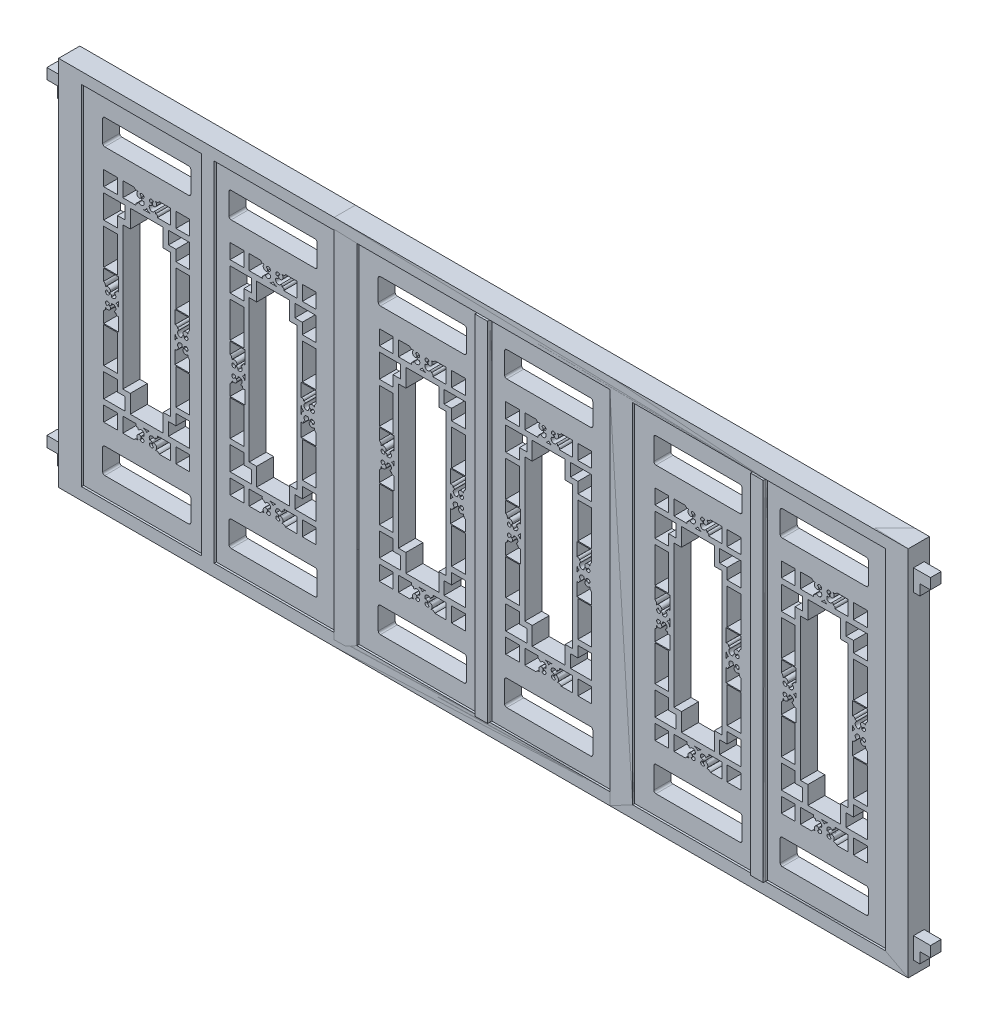
from build123d import *

# Parameters (mm, degrees)
SKETCH1_W                = 595
SKETCH1_H                = 1640
BOSS_EXTRUDE1_DEPTH      = 180
SKETCH_6_W               = 595
SKETCH_6_H               = 1640
CUT_EXTRUDE_2_DEPTH      = 100
CUT_EXTRUDE_3_DEPTH      = 100
SKETCH2_W                = 65
SKETCH2_H                = 70
SKETCH2_H_2              = 167
CUT_EXTRUDE_5_DEPTH      = 81
CUT_EXTRUDE_8_DEPTH      = 81
PATTERN_LINEAR_1_COUNT   = 2
PATTERN_LINEAR_1_PITCH   = 595
SKETCH_7_W               = 4000
SKETCH_7_H               = 1750
SKETCH_7_W_2             = 1190
SKETCH_7_H_2             = 1640
EXTRUDE_2_DEPTH          = 90
EXTRUDE_2_DEPTH_BACK     = 10
EXTRUDE_3_DEPTH          = 10
EXTRUDE_3_DEPTH_BACK     = 90
SKETCH_9_W               = 60
SKETCH_9_H               = 1640
EXTRUDE_4_DEPTH          = 100
PATTERN_LINEAR_2_COUNT   = 3
PATTERN_LINEAR_2_PITCH   = 1297.5
SKETCH_11_W              = 2595
SKETCH_11_H              = 1750
CUT_EXTRUDE_9_DEPTH      = 111
SKETCH_12_W              = 50
SKETCH_12_H              = 100
EXTRUDE_5_DEPTH          = 80
SKETCH_13_W              = 50
SKETCH_13_H              = 50
CUT_EXTRUDE_10_DEPTH     = 50
PATTERN_LINEAR_3_COUNT   = 2
PATTERN_LINEAR_3_PITCH   = 1500
MIRROR_4_COPY_1_SKETCH_W = 50
MIRROR_4_COPY_1_SKETCH_H = 100
MIRROR_4_COPY_1_DEPTH    = 80
MIRROR_4_COPY_2_SKETCH_W = 50
MIRROR_4_COPY_2_SKETCH_H = 50
MIRROR_4_COPY_2_DEPTH    = 50


with BuildPart() as part:
    # Sketch1 → Boss-Extrude1 (new body)
    with BuildSketch(Plane.XY):
        with Locations((297.5, 820)):
            Rectangle(SKETCH1_W, SKETCH1_H)
    extrude(amount=BOSS_EXTRUDE1_DEPTH)

    # Sketch 6 → Cut-Extrude 2 (cut)
    with BuildSketch(Plane.XY.offset(180)):
        with Locations((297.5, 820)):
            Rectangle(SKETCH_6_W, SKETCH_6_H)
    extrude(amount=-CUT_EXTRUDE_2_DEPTH, mode=Mode.SUBTRACT)

    # Sketch 1 → Cut-Extrude 3 (cut)
    with BuildSketch(Plane(origin=(0, 0, 0), x_dir=(-1, 0, 0), z_dir=(0, 0, -1))):
        with BuildLine():
            ThreePointArc((-339.478697135, 363.442307012), (-347.464207716, 366.462464977), (-347.449072001, 375))
            Line((-347.449072001, 375), (-410, 375))
            Line((-410, 375), (-410, 305))
            Line((-410, 305), (-356.673331708, 305))
            ThreePointArc((-356.673331708, 305), (-348.94904931, 312.012889726), (-338.529552639, 312.541330816))
            ThreePointArc((-338.529552639, 312.541330816), (-344.046220029, 325.924483031), (-334.768909443, 337.036363636))
            ThreePointArc((-334.768909443, 337.036363636), (-323.949287324, 331.726907665), (-329.315168468, 320.935157804))
            ThreePointArc((-329.315168468, 320.935157804), (-314.478603669, 315.069270244), (-315.214046212, 331.006378394))
            ThreePointArc((-315.214046212, 331.006378394), (-318.365986632, 330.765395418), (-320.358708006, 328.311447022))
            ThreePointArc((-320.358708006, 328.311447022), (-320.882047686, 338.069212343), (-311.577227356, 341.053870966))
            ThreePointArc((-311.577227356, 341.053870966), (-311.192434776, 341.798442865), (-310.72696898, 342.495432272))
            ThreePointArc((-310.72696898, 342.495432272), (-316.343126273, 360.498534643), (-334.477239272, 355.321000146))
            ThreePointArc((-334.477239272, 355.321000146), (-338.751843962, 358.289222889), (-339.478697135, 363.442307012))
        make_face()
        with BuildLine():
            Line((-185, 375), (-247.550927999, 375))
            ThreePointArc((-247.550927999, 375), (-247.535792284, 366.462464977), (-255.521302865, 363.442307012))
            ThreePointArc((-255.521302865, 363.442307012), (-256.248156038, 358.289222889), (-260.522760728, 355.321000146))
            ThreePointArc((-260.522760728, 355.321000146), (-278.656873727, 360.498534643), (-284.27303102, 342.495432272))
            ThreePointArc((-284.27303102, 342.495432272), (-283.807565224, 341.798442865), (-283.422772644, 341.053870966))
            ThreePointArc((-283.422772644, 341.053870966), (-274.117952314, 338.069212343), (-274.641291994, 328.311447022))
            ThreePointArc((-274.641291994, 328.311447022), (-276.634013368, 330.765395418), (-279.785953788, 331.006378394))
            ThreePointArc((-279.785953788, 331.006378394), (-280.521396331, 315.069270244), (-265.684831532, 320.935157804))
            ThreePointArc((-265.684831532, 320.935157804), (-271.050712676, 331.726907665), (-260.231090557, 337.036363636))
            ThreePointArc((-260.231090557, 337.036363636), (-250.953779971, 325.924483031), (-256.470447361, 312.541330816))
            ThreePointArc((-256.470447361, 312.541330816), (-246.05095069, 312.012889726), (-238.326668292, 305))
            Line((-238.326668292, 305), (-185, 305))
            Line((-185, 305), (-185, 375))
        make_face()
        with BuildLine():
            ThreePointArc((-279.5, 375), (-290.126074317, 371.412833197), (-297.5, 362.9626))
            ThreePointArc((-297.5, 362.9626), (-304.873925683, 371.412833197), (-315.5, 375))
            Line((-315.5, 375), (-279.5, 375))
        make_face()
    cut_extrude_3 = extrude(amount=-CUT_EXTRUDE_3_DEPTH, mode=Mode.SUBTRACT)

    # Sketch2 → Cut-Extrude 5 (cut, through all)
    with BuildSketch(Plane(origin=(0, 0, 0), x_dir=(-1, 0, 0), z_dir=(0, 0, -1))):
        with BuildLine():
            Line((-100, 90), (-495, 90))
            ThreePointArc((-495, 90), (-502.071067812, 92.928932188), (-505, 100))
            Line((-505, 100), (-505, 200))
            ThreePointArc((-505, 200), (-502.071067812, 207.071067812), (-495, 210))
            Line((-495, 210), (-100, 210))
            ThreePointArc((-100, 210), (-92.928932188, 207.071067812), (-90, 200))
            Line((-90, 200), (-90, 100))
            ThreePointArc((-90, 100), (-92.928932188, 92.928932188), (-100, 90))
        make_face()
        with Locations((-467.5, 340)):
            Rectangle(SKETCH2_W, SKETCH2_H)
        with Locations((-127.5, 340)):
            Rectangle(SKETCH2_W, SKETCH2_H)
        Polygon((-435, 511), (-500, 511), (-500, 400), (-400, 400), (-400, 460), (-435, 460), align=None)
        Polygon((-195, 460), (-195, 400), (-95, 400), (-95, 511), (-160, 511), (-160, 460), align=None)
        with Locations((-467.5, 619.5)):
            Rectangle(SKETCH2_W, SKETCH2_H_2)
        with Locations((-127.5, 619.5)):
            Rectangle(SKETCH2_W, SKETCH2_H_2)
        Polygon((-220, 1240), (-375, 1240), (-375, 1155), (-410, 1155), (-410, 485), (-375, 485), (-375, 400), (-220, 400), (-220, 485), (-185, 485), (-185, 1155), (-220, 1155), align=None)
        with Locations((-467.5, 1020.5)):
            Rectangle(SKETCH2_W, SKETCH2_H_2)
        with Locations((-127.5, 1020.5)):
            Rectangle(SKETCH2_W, SKETCH2_H_2)
        Polygon((-95, 1240), (-195, 1240), (-195, 1180), (-160, 1180), (-160, 1129), (-95, 1129), align=None)
        with Locations((-127.5, 1300)):
            Rectangle(SKETCH2_W, SKETCH2_H)
        with Locations((-467.5, 1300)):
            Rectangle(SKETCH2_W, SKETCH2_H)
        Polygon((-400, 1240), (-500, 1240), (-500, 1129), (-435, 1129), (-435, 1180), (-400, 1180), align=None)
        with BuildLine():
            Line((-495, 1430), (-100, 1430))
            ThreePointArc((-100, 1430), (-92.928932188, 1432.928932188), (-90, 1440))
            Line((-90, 1440), (-90, 1540))
            ThreePointArc((-90, 1540), (-92.928932188, 1547.071067812), (-100, 1550))
            Line((-100, 1550), (-495, 1550))
            ThreePointArc((-495, 1550), (-502.071067812, 1547.071067812), (-505, 1540))
            Line((-505, 1540), (-505, 1440))
            ThreePointArc((-505, 1440), (-502.071067812, 1432.928932188), (-495, 1430))
        make_face()
    extrude(amount=-CUT_EXTRUDE_5_DEPTH, mode=Mode.SUBTRACT)

    # Mirror 1: Cut-Extrude 3 across plane
    add(cut_extrude_3.mirror(Plane.ZX.offset(820)), mode=Mode.SUBTRACT)

    # Sketch 1_5 → Cut-Extrude 8 (cut, through all)
    with BuildSketch(Plane(origin=(0, 0, 0), x_dir=(-1, 0, 0), z_dir=(0, 0, -1))):
        with BuildLine():
            Line((-430, 869.949072001), (-430, 932.5))
            Line((-430, 932.5), (-500, 932.5))
            Line((-500, 932.5), (-500, 879.173331708))
            ThreePointArc((-500, 879.173331708), (-492.987110274, 871.44904931), (-492.458669184, 861.029552639))
            ThreePointArc((-492.458669184, 861.029552639), (-479.075516969, 866.546220029), (-467.963636364, 857.268909443))
            ThreePointArc((-467.963636364, 857.268909443), (-473.273092335, 846.449287324), (-484.064842196, 851.815168468))
            ThreePointArc((-484.064842196, 851.815168468), (-489.930729756, 836.978603669), (-473.993621606, 837.714046212))
            ThreePointArc((-473.993621606, 837.714046212), (-474.234604582, 840.865986631), (-476.688552978, 842.858708006))
            ThreePointArc((-476.688552978, 842.858708006), (-466.930787657, 843.382047686), (-463.946129034, 834.077227356))
            ThreePointArc((-463.946129034, 834.077227356), (-463.201557135, 833.692434776), (-462.504567728, 833.22696898))
            ThreePointArc((-462.504567728, 833.22696898), (-444.501465357, 838.843126273), (-449.678999854, 856.977239272))
            ThreePointArc((-449.678999854, 856.977239272), (-446.710777111, 861.251843962), (-441.557692988, 861.978697135))
            ThreePointArc((-441.557692988, 861.978697135), (-438.537535023, 869.964207716), (-430, 869.949072001))
        make_face()
        with BuildLine():
            Line((-500, 760.826668292), (-500, 707.5))
            Line((-500, 707.5), (-430, 707.5))
            Line((-430, 707.5), (-430, 770.050927999))
            ThreePointArc((-430, 770.050927999), (-438.537535023, 770.035792284), (-441.557692988, 778.021302865))
            ThreePointArc((-441.557692988, 778.021302865), (-446.710777111, 778.748156038), (-449.678999854, 783.022760728))
            ThreePointArc((-449.678999854, 783.022760728), (-444.501465357, 801.156873727), (-462.504567728, 806.77303102))
            ThreePointArc((-462.504567728, 806.77303102), (-463.201557135, 806.307565224), (-463.946129034, 805.922772644))
            ThreePointArc((-463.946129034, 805.922772644), (-466.930787657, 796.617952314), (-476.688552978, 797.141291994))
            ThreePointArc((-476.688552978, 797.141291994), (-474.234604582, 799.134013368), (-473.993621606, 802.285953788))
            ThreePointArc((-473.993621606, 802.285953788), (-489.930729756, 803.021396331), (-484.064842196, 788.184831532))
            ThreePointArc((-484.064842196, 788.184831532), (-473.273092335, 793.550712676), (-467.963636364, 782.731090557))
            ThreePointArc((-467.963636364, 782.731090557), (-479.075516969, 773.453779971), (-492.458669184, 778.970447361))
            ThreePointArc((-492.458669184, 778.970447361), (-492.987110274, 768.55095069), (-500, 760.826668292))
        make_face()
        with BuildLine():
            ThreePointArc((-442.0374, 820), (-433.587166803, 827.373925683), (-430, 838))
            Line((-430, 838), (-430, 802))
            ThreePointArc((-430, 802), (-433.587166803, 812.626074317), (-442.0374, 820))
        make_face()
    cut_extrude_8 = extrude(amount=-CUT_EXTRUDE_8_DEPTH, mode=Mode.SUBTRACT)

    # Mirror 3: Cut-Extrude 8 across plane
    add(cut_extrude_8.mirror(Plane.ZY.offset(-297.5)), mode=Mode.SUBTRACT)


with BuildPart() as pattern_linear_1_1:
    # Pattern Linear 1: pattern copy
    add(part.part.moved(Location(Vector(1, 0, 0) * (1 * PATTERN_LINEAR_1_PITCH))))


with BuildPart() as part_1:
    add(part.part)

    add(pattern_linear_1_1.part)  # Extrude 2 merges Pattern Linear 1_1
    # Sketch 7 → Extrude 2 (add, two sides)
    with BuildSketch(Plane.XY) as extrude_2_sk:
        with Locations((1892.5, 817.5)):
            Rectangle(SKETCH_7_W, SKETCH_7_H)
        with Locations((1892.5, 820)):
            Rectangle(SKETCH_7_W_2, SKETCH_7_H_2, mode=Mode.SUBTRACT)
        with Locations((595, 820)):
            Rectangle(SKETCH_7_W_2, SKETCH_7_H_2, mode=Mode.SUBTRACT)
        with Locations((3190, 820)):
            Rectangle(SKETCH_7_W_2, SKETCH_7_H_2, mode=Mode.SUBTRACT)
    extrude(amount=EXTRUDE_2_DEPTH)
    extrude(extrude_2_sk.sketch, amount=-EXTRUDE_2_DEPTH_BACK)

    # Sketch 8 → Extrude 3 (add, two sides)
    with BuildSketch(Plane(origin=(0, 0, 0), x_dir=(-1, 0, 0), z_dir=(0, 0, -1))) as extrude_3_sk:
        Polygon((-595, 1640), (-565, 1640), (-565, 0), (-625, 0), (-625, 1640), align=None)
    extrude(amount=EXTRUDE_3_DEPTH)
    extrude(extrude_3_sk.sketch, amount=-EXTRUDE_3_DEPTH_BACK)

    # Sketch 9 → Extrude 4 (add)
    with BuildSketch(Plane.XY):
        with Locations((1892.5, 820)):
            Rectangle(SKETCH_9_W, SKETCH_9_H)
        with Locations((3190, 820)):
            Rectangle(SKETCH_9_W, SKETCH_9_H)
    extrude(amount=EXTRUDE_4_DEPTH)


with BuildPart() as pattern_linear_2_1:
    # Pattern Linear 2: pattern copy
    add(part_1.part.moved(Location(Vector(1, 0, 0) * (1 * PATTERN_LINEAR_2_PITCH))))


with BuildPart() as pattern_linear_2_2:
    # Pattern Linear 2: pattern copy
    add(part_1.part.moved(Location(Vector(1, 0, 0) * (2 * PATTERN_LINEAR_2_PITCH))))


with BuildPart() as cut_extrude_9_tool:
    # Sketch 11 → Cut-Extrude 9 (new body, through all)
    with BuildSketch(Plane.XY.offset(100)):
        with Locations((5190, 817.5)):
            Rectangle(SKETCH_11_W, SKETCH_11_H)
    extrude(amount=-CUT_EXTRUDE_9_DEPTH)


with BuildPart() as pattern_linear_2_1_1:
    add(pattern_linear_2_1.part)

    # Cut-Extrude 9: cut by cut_extrude_9_tool
    add(cut_extrude_9_tool.part, mode=Mode.SUBTRACT)


with BuildPart() as pattern_linear_2_2_1:
    add(pattern_linear_2_2.part)

    # Cut-Extrude 9: cut by cut_extrude_9_tool
    add(cut_extrude_9_tool.part, mode=Mode.SUBTRACT)


with BuildPart() as part_2:
    add(part_1.part)

    # Sketch 12 → Extrude 5 (add)
    with BuildSketch(Plane.ZY.offset(107.5)):
        with Locations((40, 52.5)):
            Rectangle(SKETCH_12_W, SKETCH_12_H)
    extrude_5 = extrude(amount=EXTRUDE_5_DEPTH)

    # Sketch 13 → Cut-Extrude 10 (cut)
    with BuildSketch(Plane.ZY.offset(187.5)):
        with Locations((40, 27.5)):
            Rectangle(SKETCH_13_W, SKETCH_13_H)
    cut_extrude_10 = extrude(amount=-CUT_EXTRUDE_10_DEPTH, mode=Mode.SUBTRACT)

    # Pattern Linear 3: Extrude 5, Cut-Extrude 10 ×2
    with Locations(*[(0, i * PATTERN_LINEAR_3_PITCH, 0) for i in range(1, PATTERN_LINEAR_3_COUNT)]):
        add(extrude_5)
        add(cut_extrude_10, mode=Mode.SUBTRACT)

    # Mirror 4: Extrude 5, Cut-Extrude 10 across plane
    add(extrude_5.mirror(Plane(origin=(1892.5, -57.5, 90), x_dir=(0, 0, 1), z_dir=(-1, 0, 0))))
    add(cut_extrude_10.mirror(Plane(origin=(1892.5, -57.5, 90), x_dir=(0, 0, 1), z_dir=(-1, 0, 0))), mode=Mode.SUBTRACT)

    # Mirror 4 copy 1 sketch → Mirror 4 copy 1 (add)
    with BuildSketch(Plane(origin=(3892.5, 1500, 0), x_dir=(0, 0, 1), z_dir=(1, 0, 0))):
        with Locations((40, -52.5)):
            Rectangle(MIRROR_4_COPY_1_SKETCH_W, MIRROR_4_COPY_1_SKETCH_H)
    extrude(amount=MIRROR_4_COPY_1_DEPTH)

    # Mirror 4 copy 2 sketch → Mirror 4 copy 2 (cut)
    with BuildSketch(Plane(origin=(3972.5, 1500, 0), x_dir=(0, 0, 1), z_dir=(1, 0, 0))):
        with Locations((40, -27.5)):
            Rectangle(MIRROR_4_COPY_2_SKETCH_W, MIRROR_4_COPY_2_SKETCH_H)
    extrude(amount=-MIRROR_4_COPY_2_DEPTH, mode=Mode.SUBTRACT)


solid = Compound([pattern_linear_2_1_1.part, pattern_linear_2_2_1.part, part_2.part])
